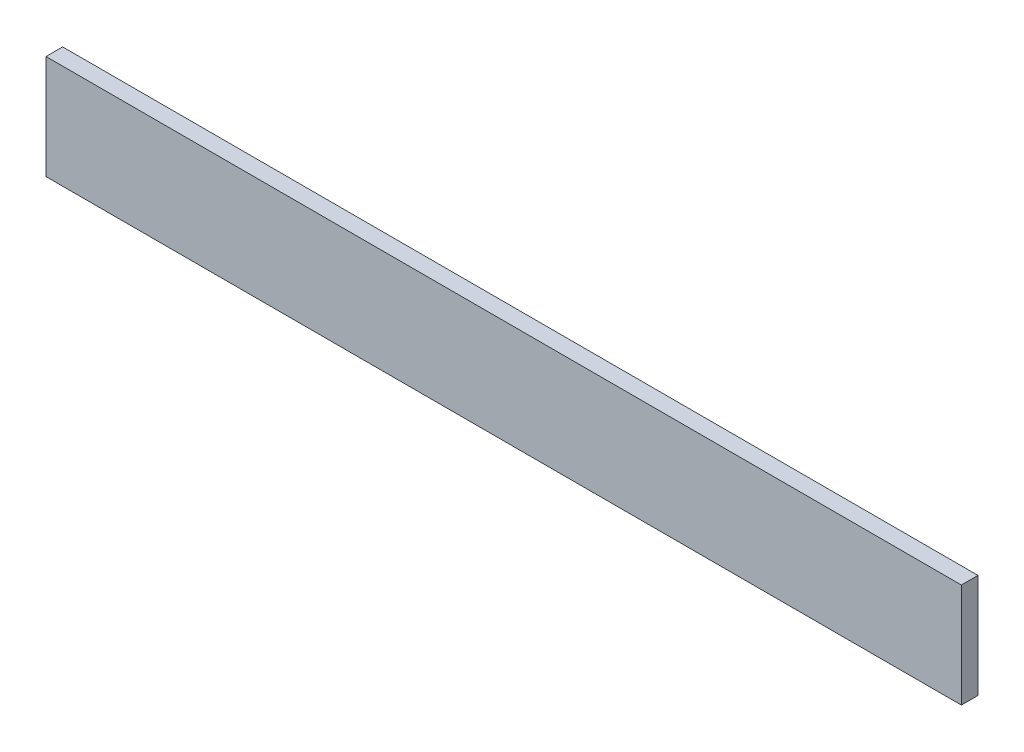
from build123d import *

# Parameters (mm, degrees)
SKETCH1_W           = 220
SKETCH1_H           = 25
BOSS_EXTRUDE1_DEPTH = 4


with BuildPart() as part:
    # Sketch1 → Boss-Extrude1 (new body)
    with BuildSketch(Plane.XY):
        with Locations((-0.913276477, 18.538320847)):
            Rectangle(SKETCH1_W, SKETCH1_H)
    extrude(amount=BOSS_EXTRUDE1_DEPTH)


solid = part.part
